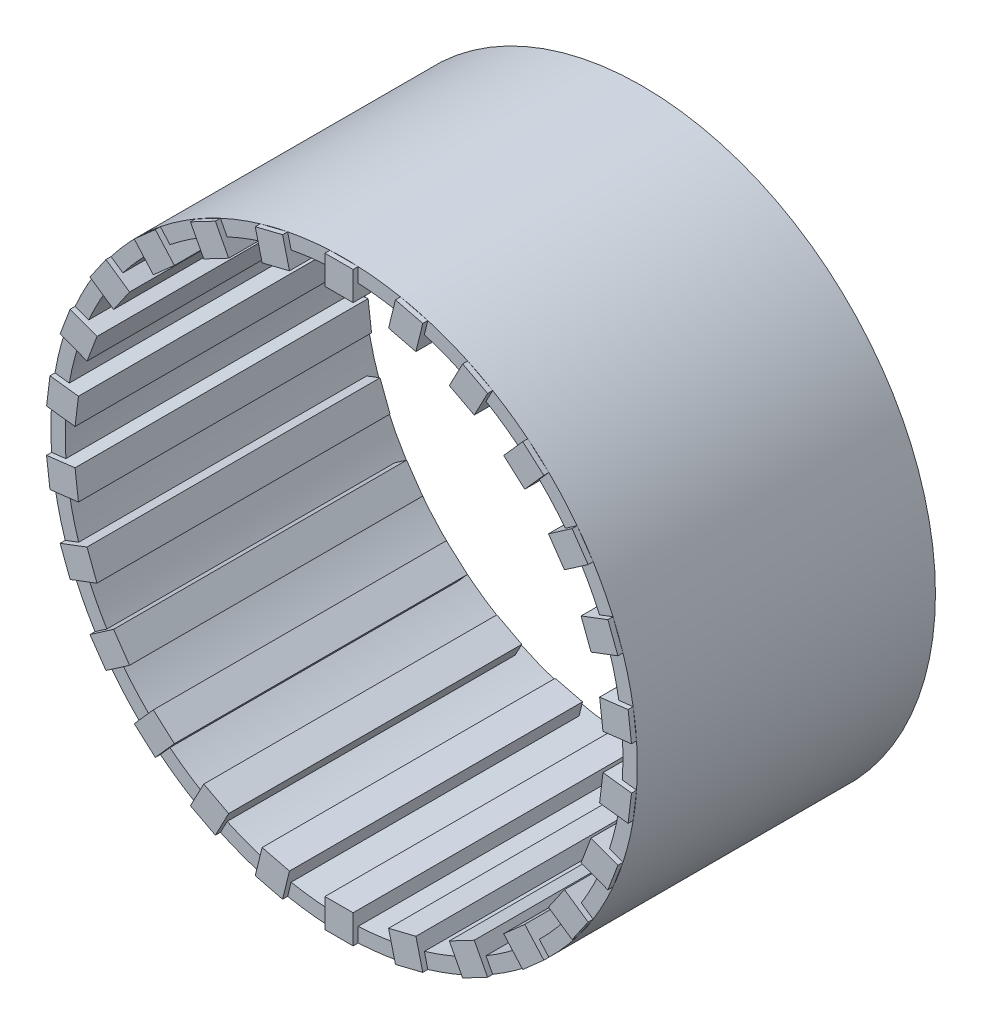
from build123d import *

# Parameters (mm, degrees)
SKETCH1_R           = 14.741067144
SKETCH1_R_2         = 14.017377528
BOSS_EXTRUDE2_DEPTH = 14.986
BOSS_EXTRUDE3_START = -14.478
BOSS_EXTRUDE3_DEPTH = 14.732
CIRPATTERN1_COUNT   = 26


with BuildPart() as part:
    # Sketch1 → Boss-Extrude2 (new body)
    with BuildSketch(Plane.XY):
        Circle(SKETCH1_R)
        Circle(SKETCH1_R_2, mode=Mode.SUBTRACT)
    extrude(amount=BOSS_EXTRUDE2_DEPTH)

    # Sketch2 → Boss-Extrude3 (add)
    with BuildSketch(Plane.XY.offset(14.986).offset(BOSS_EXTRUDE3_START)):
        Polygon((0, 13.280428126), (0.707736778, 13.280428126), (0.707736778, 14.724067685), (-0.707736778, 14.724067685), (-0.707736778, 13.280428126), align=None)
    boss_extrude3 = extrude(amount=BOSS_EXTRUDE3_DEPTH)

    # CirPattern1: Boss-Extrude3 ×26 about axis
    cirpattern1_axis = Axis((0, 0, 0), (0, 0, 1))
    for i in range(1, CIRPATTERN1_COUNT):
        add(boss_extrude3.rotate(cirpattern1_axis, i * 360 / CIRPATTERN1_COUNT))


solid = part.part
